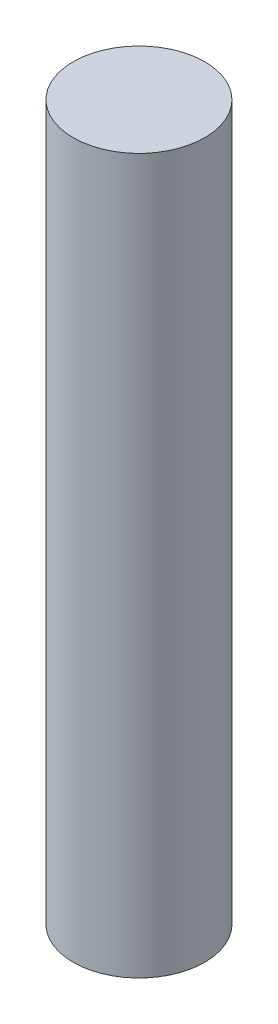
from build123d import *

# Parameters (mm, degrees)
SKETCH1_R           = 44.45
BOSS_EXTRUDE1_DEPTH = 482.6


with BuildPart() as part:
    # Sketch1 → Boss-Extrude1 (new body)
    with BuildSketch(Plane(origin=(0, 0, 0), x_dir=(1, 0, 0), z_dir=(0, 1, 0))):
        Circle(SKETCH1_R)
    extrude(amount=BOSS_EXTRUDE1_DEPTH)


solid = part.part
